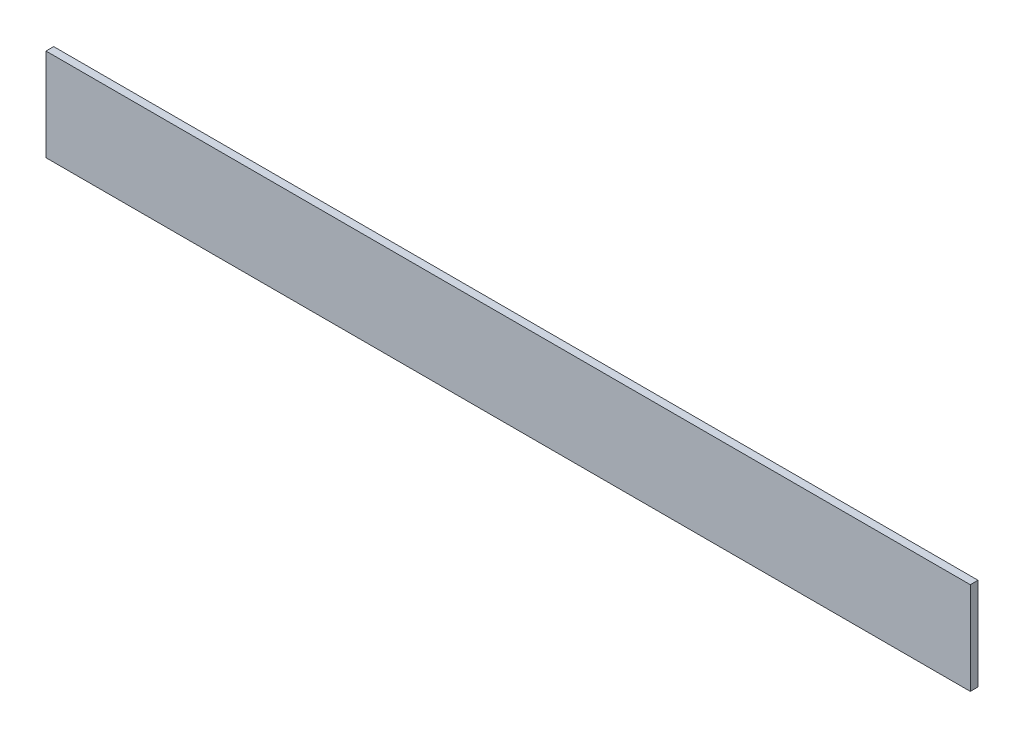
from build123d import *

# Parameters (mm, degrees)
SKETCH1_W           = 6.35
SKETCH1_H           = 76.2
BOSS_EXTRUDE1_DEPTH = 762


with BuildPart() as part:
    # Sketch1 → Boss-Extrude1 (new body)
    with BuildSketch(Plane(origin=(0, 0, 0), x_dir=(0, 0, -1), z_dir=(1, 0, 0))):
        Rectangle(SKETCH1_W, SKETCH1_H)
    extrude(amount=BOSS_EXTRUDE1_DEPTH)


solid = part.part
